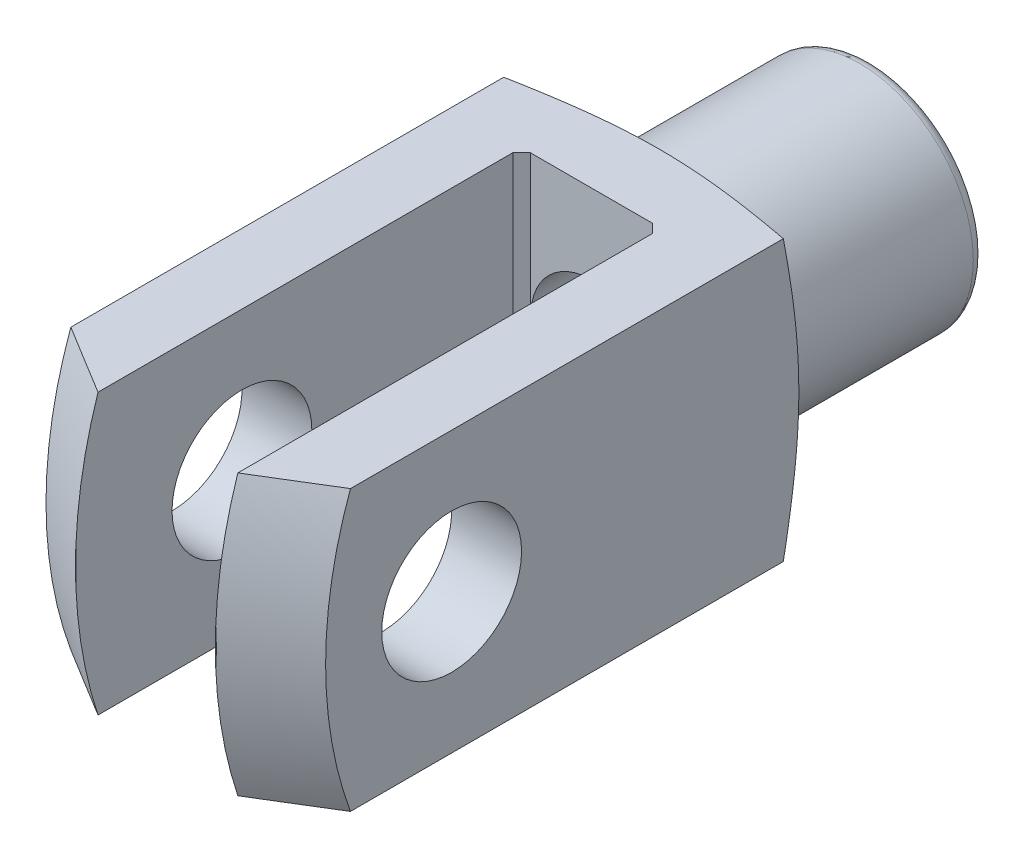
from build123d import *

# Parameters (mm, degrees)
CUT_EXTRUDE1_DEPTH           = 33
CUT_EXTRUDE1_DEPTH_BACK      = 33
CUT_EXTRUDE2_DEPTH           = 33
CUT_EXTRUDE2_DEPTH_BACK      = 33
CUT_EXTRUDE3_DEPTH           = 33
CUT_EXTRUDE3_DEPTH_BACK      = 33
SKETCH5_W                    = 39.5
SKETCH5_H                    = 8
CUT_REVOLVE3_ANGLE           = 90
CUT_REVOLVE3_OTHER_WAY_ANGLE = 90


with BuildPart() as part:
    # Sketch1 → Revolve1 (revolve)
    with BuildSketch(Plane(origin=(0, 0, 0), x_dir=(0, 0, -1), z_dir=(1, 0, 0))):
        with BuildLine():
            Line((-19, 0), (-19, 32))
            Line((-19, 32), (35.444863729, 32))
            Line((35.444863729, 32), (40, 15))
            ThreePointArc((40, 15), (40.585786438, 13.585786438), (42, 13))
            Line((42, 13), (62.7, 13))
            ThreePointArc((62.7, 13), (63.619238816, 12.619238816), (64, 11.7))
            Line((64, 11.7), (64, 0))
            Line((64, 0), (-19, 0))
        make_face()
    revolve(axis=Axis((0, 0, -64), (0, 0, 1)))

    # Sketch2 → Cut-Extrude1 (cut, two sides: drawn at the far end of the back side and taken through both)
    with BuildSketch(Plane(origin=(0, 0, 0), x_dir=(1, 0, 0), z_dir=(0, 1, 0)).offset(-CUT_EXTRUDE1_DEPTH_BACK)):
        Polygon((-8, 31), (-8, -20), (8, -20), (8, 31), (7, 32), (-7, 32), align=None)
    extrude(amount=CUT_EXTRUDE1_DEPTH + CUT_EXTRUDE1_DEPTH_BACK, mode=Mode.SUBTRACT)

    # Sketch3 → Cut-Extrude2 (cut, two sides: drawn at the far end of the back side and taken through both)
    with BuildSketch(Plane(origin=(0, 0, 0), x_dir=(0, 0, -1), z_dir=(1, 0, 0)).offset(-CUT_EXTRUDE2_DEPTH_BACK)):
        Polygon((-52, -48), (64, -48), (64, -16), (-20, -16), (-20, 16), (64, 16), (64, 48), (-52, 48), align=None)
    extrude(amount=CUT_EXTRUDE2_DEPTH + CUT_EXTRUDE2_DEPTH_BACK, mode=Mode.SUBTRACT)

    # Sketch4 → Cut-Extrude3 (cut, two sides: drawn at the far end of the back side and taken through both)
    with BuildSketch(Plane(origin=(0, 0, 0), x_dir=(1, 0, 0), z_dir=(0, 1, 0)).offset(-CUT_EXTRUDE3_DEPTH_BACK)):
        Polygon((-48, -52), (48, -52), (48, 64), (16, 64), (16, -20), (-16, -20), (-16, 64), (-48, 64), align=None)
    extrude(amount=CUT_EXTRUDE3_DEPTH + CUT_EXTRUDE3_DEPTH_BACK, mode=Mode.SUBTRACT)

    # Sketch5 → Cut-Revolve1 (revolve, cut)
    with BuildSketch(Plane.XY):
        with Locations((0, 4)):
            Rectangle(SKETCH5_W, SKETCH5_H)
    revolve(axis=Axis((19.75, 0, 0), (-1, 0, 0)), mode=Mode.SUBTRACT)

    # Sketch6 → Cut-Revolve2 (revolve, cut)
    with BuildSketch(Plane(origin=(0, 0, 0), x_dir=(0, 0, -1), z_dir=(1, 0, 0))):
        Polygon((30.9, 0), (30.9, 6.9175), (63.0175, 6.9175), (64.1, 8), (64.1, 0), align=None)
    revolve(axis=Axis((0, 0, -64.1), (0, 0, 1)), mode=Mode.SUBTRACT)

    # Sketch7 → Cut-Revolve3 (revolve, cut)
    with BuildSketch(Plane(origin=(0, 0, 0), x_dir=(1, 0, 0), z_dir=(0, 1, 0))):
        Polygon((-19, -49.64182924), (0, -60.611484355), (19, -49.64182924), (19, -12.691412012), (0, -23.661067127), (-19, -12.691412012), align=None)
    revolve(axis=Axis((-19, 0, -32), (-1, 0, 0)), revolution_arc=CUT_REVOLVE3_ANGLE, mode=Mode.SUBTRACT)

    # Sketch7 → Cut-Revolve3 other way (revolve, cut)
    with BuildSketch(Plane(origin=(0, 0, 0), x_dir=(1, 0, 0), z_dir=(0, 1, 0))):
        Polygon((-19, -49.64182924), (0, -60.611484355), (19, -49.64182924), (19, -12.691412012), (0, -23.661067127), (-19, -12.691412012), align=None)
    revolve(axis=Axis((-19, 0, -32), (1, 0, 0)), revolution_arc=CUT_REVOLVE3_OTHER_WAY_ANGLE, mode=Mode.SUBTRACT)


solid = part.part
